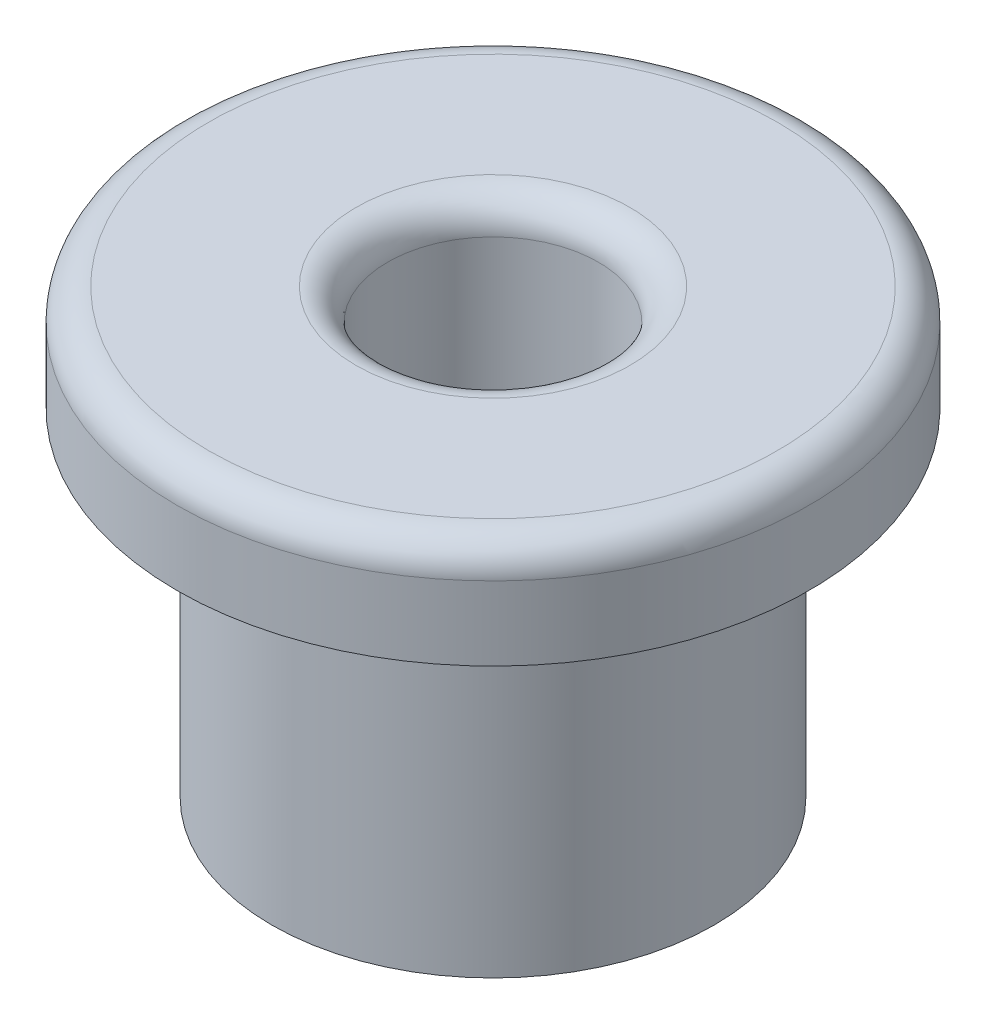
from build123d import *

# Parameters (mm, degrees)
SKETCH_1_R      = 2.1
SKETCH_1_R_2    = 1
EXTRUDE_1_DEPTH = 4.2
SKETCH_2_R      = 3
SKETCH_2_R_2    = 2.1
EXTRUDE_3_DEPTH = 1
FILLET_1_R      = 0.3


with BuildPart() as part:
    # 草图1 → 凸台-拉伸1 (new body)
    with BuildSketch(Plane(origin=(0, 0, 0), x_dir=(1, 0, 0), z_dir=(0, 1, 0))):
        Circle(SKETCH_1_R)
        Circle(SKETCH_1_R_2, mode=Mode.SUBTRACT)
    extrude(amount=EXTRUDE_1_DEPTH)

    # 草图2 → 凸台-拉伸3 (add)
    with BuildSketch(Plane(origin=(0, 4.2, 0), x_dir=(1, 0, 0), z_dir=(0, 1, 0))):
        Circle(SKETCH_2_R)
        Circle(SKETCH_2_R_2, mode=Mode.SUBTRACT)
    extrude(amount=-EXTRUDE_3_DEPTH)

    # 圆角1
    fillet_1_edges = [part.edges().sort_by_distance(p)[0] for p in [
        (-3, 4.2, 0),
        (-1, 4.2, 0),
    ]]
    fillet(fillet_1_edges, radius=FILLET_1_R)


solid = part.part
